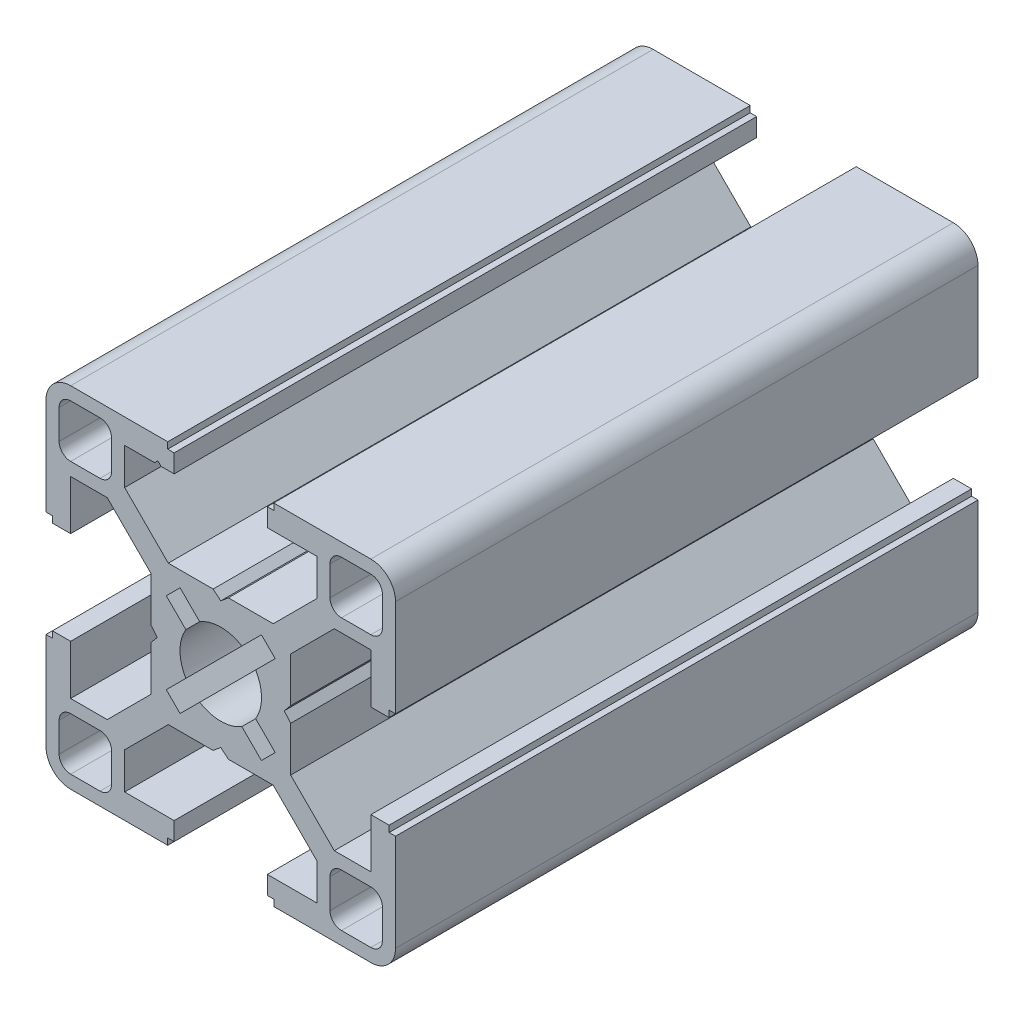
from build123d import *

# Parameters (mm, degrees)
BOSS_EXTRUDE1_DEPTH     = 25
CUT_EXTRUDE1_DEPTH      = 1
CUT_EXTRUDE1_DEPTH_BACK = 51


with BuildPart() as part:
    # Sketch4 → Boss-Extrude1 (new body, symmetric)
    with BuildSketch(Plane.XY):
        with BuildLine():
            Line((0, -5.45), (0.655464476, -6))
            Line((0.655464476, -6), (4.504469158, -6))
            Line((4.504469158, -6), (8.25, -9.745530842))
            Line((8.25, -9.745530842), (8.25, -12.885))
            Line((8.25, -12.885), (4, -12.885))
            Line((4, -12.885), (4, -14.45))
            Line((4, -14.45), (4.55, -14.45))
            Line((4.55, -14.45), (4.55, -15))
            Line((4.55, -15), (12.885, -15))
            ThreePointArc((12.885, -15), (14.380530842, -14.380530842), (15, -12.885))
            Line((15, -12.885), (15, -4.55))
            Line((15, -4.55), (14.45, -4.55))
            Line((14.45, -4.55), (14.45, -4))
            Line((14.45, -4), (12.885, -4))
            Line((12.885, -4), (12.885, -8.25))
            Line((12.885, -8.25), (9.745530842, -8.25))
            Line((9.745530842, -8.25), (6, -4.504469158))
            Line((6, -4.504469158), (6, -0.655464476))
            Line((6, -0.655464476), (5.45, 0))
            Line((5.45, 0), (3.5, 0))
            ThreePointArc((3.5, 0), (3.371433308, -0.939913534), (2.995178599, -1.81077474))
            Line((2.995178599, -1.81077474), (4.675743591, -3.491339732))
            Line((4.675743591, -3.491339732), (3.491339732, -4.675743591))
            Line((3.491339732, -4.675743591), (1.81077474, -2.995178599))
            ThreePointArc((1.81077474, -2.995178599), (0.939913534, -3.371433308), (0, -3.5))
            Line((0, -3.5), (0, -5.45))
        make_face()
        with BuildLine():
            Line((9.375, -10.365), (9.375, -12.885))
            ThreePointArc((9.375, -12.885), (9.664964287, -13.585035713), (10.365, -13.875))
            Line((10.365, -13.875), (12.885, -13.875))
            ThreePointArc((12.885, -13.875), (13.585035713, -13.585035713), (13.875, -12.885))
            Line((13.875, -12.885), (13.875, -10.365))
            ThreePointArc((13.875, -10.365), (13.585035713, -9.664964287), (12.885, -9.375))
            Line((12.885, -9.375), (10.365, -9.375))
            ThreePointArc((10.365, -9.375), (9.664964287, -9.664964287), (9.375, -10.365))
        make_face(mode=Mode.SUBTRACT)
    extrude(amount=BOSS_EXTRUDE1_DEPTH, both=True)

    # Mirror1: part across plane


with BuildPart() as part_1:
    add(part.part)
    add(part.part.mirror(Plane(origin=(0, 0, 0), x_dir=(0, 0, 1), z_dir=(1, 0, 0))))

    # Mirror2: part across plane


with BuildPart() as part_2:
    add(part_1.part)
    add(part_1.part.mirror(Plane.ZX))

    # Sketch5 → Cut-Extrude1 (cut, two sides)
    with BuildSketch(Plane.XY.offset(25)) as cut_extrude1_sk:
        Polygon((-5.675, 12.885), (-5.4, 13.16), (-5.125, 12.885), align=None)
    extrude(amount=CUT_EXTRUDE1_DEPTH, mode=Mode.SUBTRACT)
    extrude(cut_extrude1_sk.sketch, amount=-CUT_EXTRUDE1_DEPTH_BACK, mode=Mode.SUBTRACT)


solid = part_2.part
